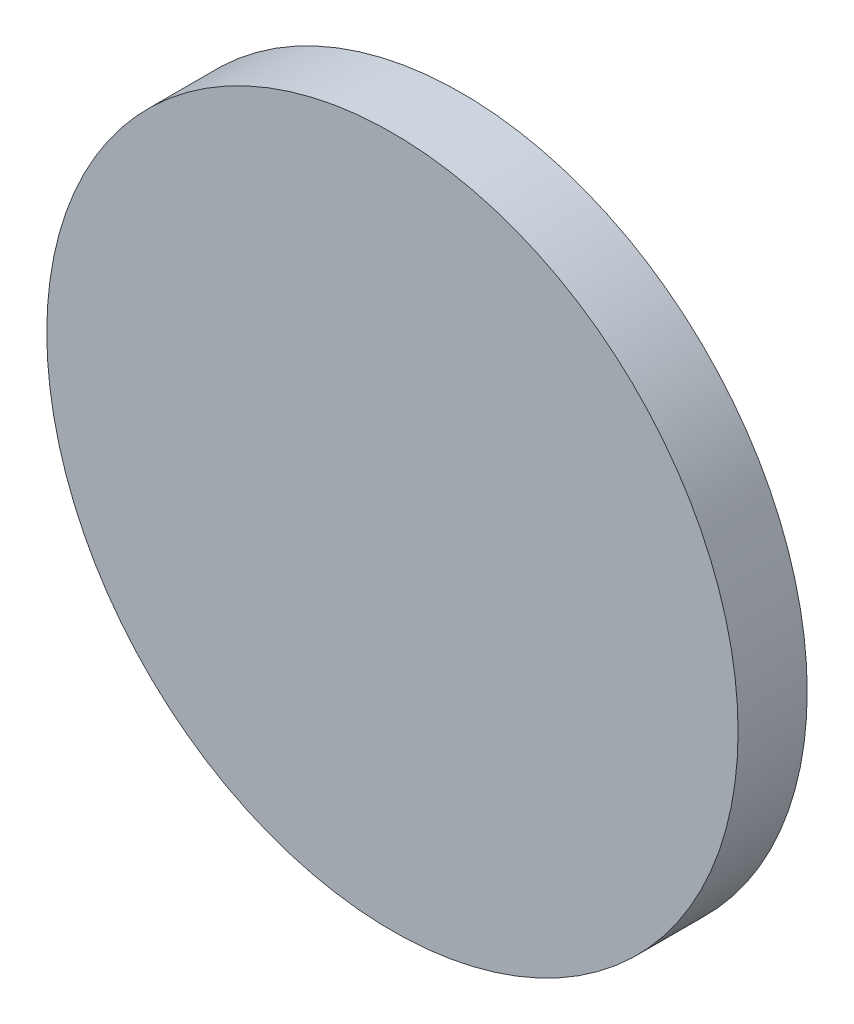
from build123d import *

# Parameters (mm, degrees)
SKETCH_1_R      = 5
EXTRUDE_1_DEPTH = 1


with BuildPart() as part:
    # 草图1 → 凸台-拉伸1 (new body)
    with BuildSketch(Plane.XY):
        Circle(SKETCH_1_R)
    extrude(amount=EXTRUDE_1_DEPTH)


solid = part.part
